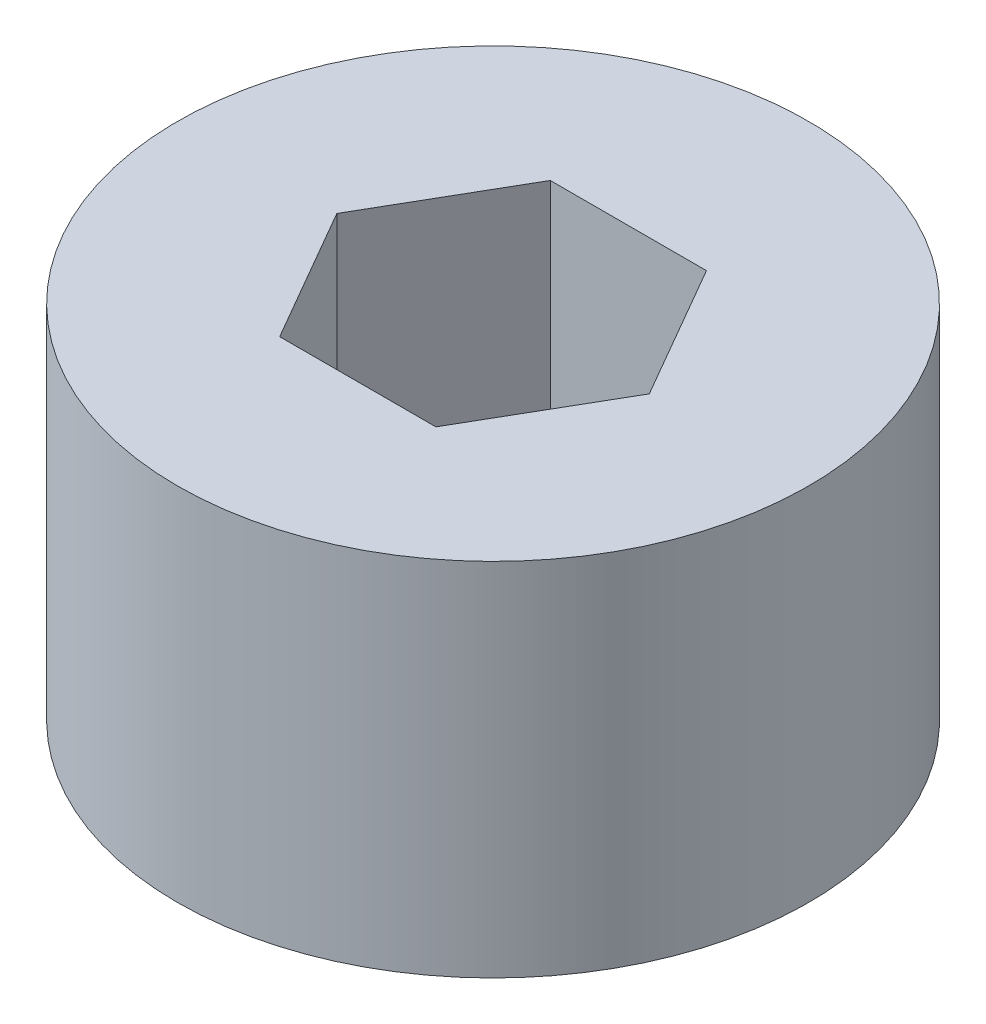
from build123d import *

# Parameters (mm, degrees)
SKETCH1_R           = 3.5
BOSS_EXTRUDE1_DEPTH = 4
SKETCH2_R           = 2
BOSS_EXTRUDE2_DEPTH = 1
CUT_EXTRUDE1_DEPTH  = 3


with BuildPart() as part:
    # Sketch1 → Boss-Extrude1 (new body)
    with BuildSketch(Plane(origin=(0, 0, 0), x_dir=(1, 0, 0), z_dir=(0, 1, 0))):
        Circle(SKETCH1_R)
    extrude(amount=BOSS_EXTRUDE1_DEPTH)

    # Sketch2 → Boss-Extrude2 (add)
    with BuildSketch(Plane.XZ):
        Circle(SKETCH2_R)
    extrude(amount=BOSS_EXTRUDE2_DEPTH)

    # Sketch3 → Cut-Extrude1 (cut)
    with BuildSketch(Plane(origin=(0, 4, 0), x_dir=(1, 0, 0), z_dir=(0, 1, 0))):
        Polygon((1.732050808, 0), (0.866025404, 1.5), (-0.866025404, 1.5), (-1.732050808, 0), (-0.866025404, -1.5), (0.866025404, -1.5), align=None)
    extrude(amount=-CUT_EXTRUDE1_DEPTH, mode=Mode.SUBTRACT)


solid = part.part
